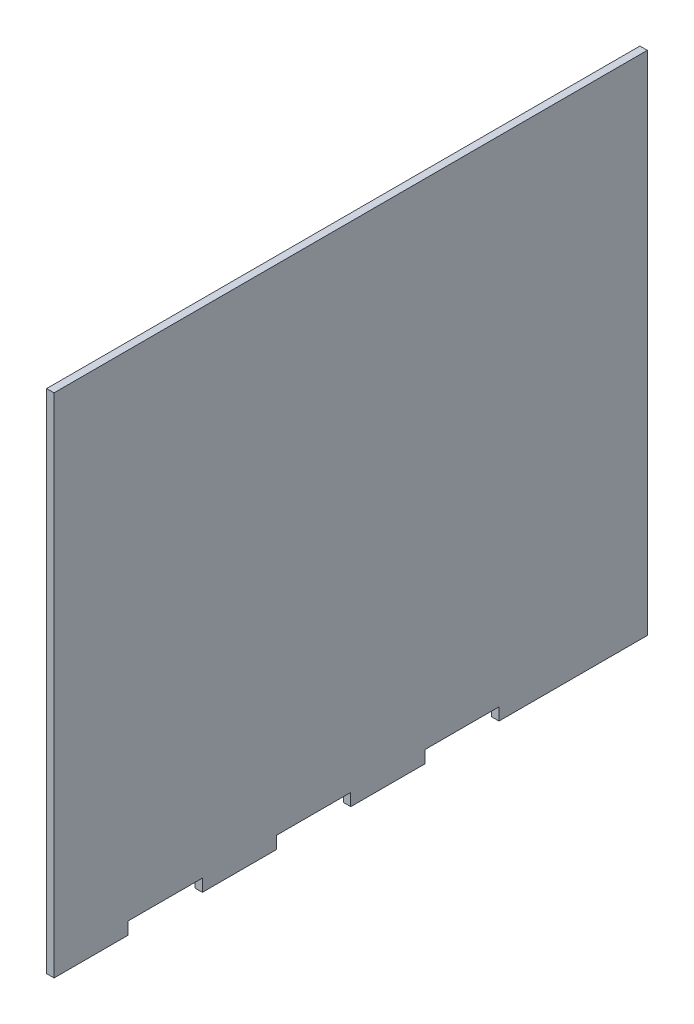
from build123d import *

# Parameters (mm, degrees)
SKETCH1_W           = 240
SKETCH1_H           = 205
BOSS_EXTRUDE1_DEPTH = 3
SKETCH2_W           = 30
SKETCH2_H           = 5
CUT_EXTRUDE1_DEPTH  = 3


with BuildPart() as part:
    # Sketch1 → Boss-Extrude1 (new body)
    with BuildSketch(Plane(origin=(0, 0, 0), x_dir=(0, 0, -1), z_dir=(1, 0, 0))):
        Rectangle(SKETCH1_W, SKETCH1_H)
    extrude(amount=BOSS_EXTRUDE1_DEPTH)

    # Sketch2 → Cut-Extrude1 (cut)
    with BuildSketch(Plane(origin=(3, 0, 0), x_dir=(0, 0, -1), z_dir=(1, 0, 0))):
        with Locations((-75, -100)):
            Rectangle(SKETCH2_W, SKETCH2_H)
        with Locations((-15, -100)):
            Rectangle(SKETCH2_W, SKETCH2_H)
        with Locations((45, -100)):
            Rectangle(SKETCH2_W, SKETCH2_H)
    extrude(amount=-CUT_EXTRUDE1_DEPTH, mode=Mode.SUBTRACT)


solid = part.part
